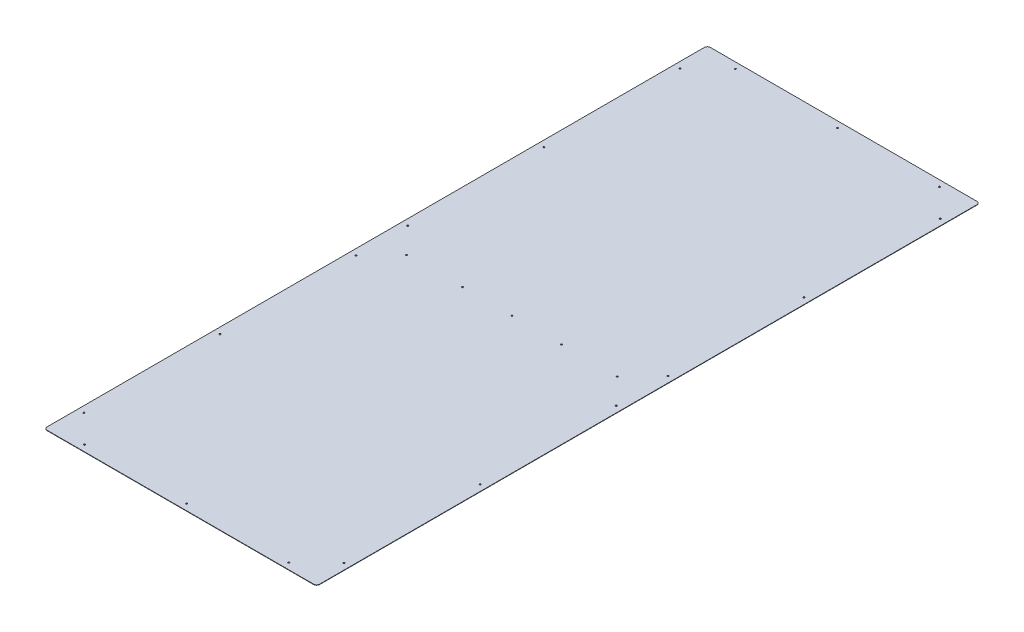
from build123d import *

# Parameters (mm, degrees)
SKETCH1_W                    = 559.1048
SKETCH1_H                    = 1360.7288
BOSS_EXTRUDE1_DEPTH          = 0.79375
FILLET1_R                    = 6.35
F_1_8_0_125_DIAMETER_HOLE1_D = 3.175


with BuildPart() as part:
    # Sketch1 → Boss-Extrude1 (new body)
    with BuildSketch(Plane(origin=(0, 0, 0), x_dir=(1, 0, 0), z_dir=(0, 1, 0))):
        Rectangle(SKETCH1_W, SKETCH1_H)
    extrude(amount=BOSS_EXTRUDE1_DEPTH)

    # Fillet1
    fillet1_edges = [part.edges().sort_by_distance(p)[0] for p in [
        (279.5524, 0.396875, 680.3644),
        (-279.5524, 0.396875, 680.3644),
        (-279.5524, 0.396875, -680.3644),
        (279.5524, 0.396875, -680.3644),
    ]]
    fillet(fillet1_edges, radius=FILLET1_R)

    # 1/8 (0.125) Diameter Hole1 (through all)
    with Locations(Plane(origin=(0, 0, 0), x_dir=(-1, 0, 0), z_dir=(0, -1, 0))):
        with Locations((-266.8524, -611.632), (-209.55, -667.6644), (-266.8524, -332.232), (0, -667.6644), (209.55, -667.6644), (266.8524, -611.632), (266.8524, -332.232), (266.8524, -52.832), (266.8524, 52.9082), (-266.8524, -52.832), (-266.8524, 52.9082), (-266.8524, 332.3082), (-266.8524, 611.7082), (-209.55, 667.7406), (0, 667.7406), (266.8524, 332.3082), (266.8524, 611.632), (209.55, 667.7406), (-216.0524, 0), (-101.7524, 0), (0, 0), (101.7524, 0), (216.0524, 0)):
            Hole(F_1_8_0_125_DIAMETER_HOLE1_D / 2)


solid = part.part
